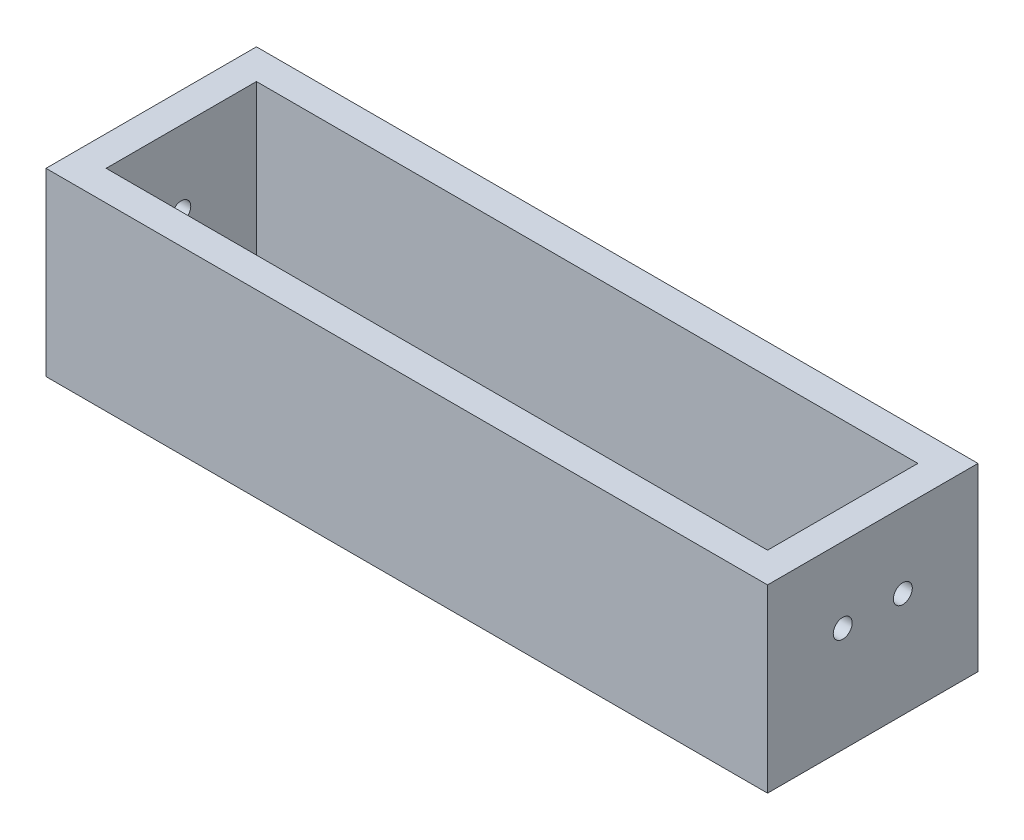
from build123d import *

# Parameters (mm, degrees)
SKETCH1_W           = 76.2
SKETCH1_H           = 22.225
BOSS_EXTRUDE1_DEPTH = 3.175
SKETCH2_W           = 3.175
SKETCH2_H           = 15.875
BOSS_EXTRUDE2_DEPTH = 15.875
SKETCH3_R           = 1
CUT_EXTRUDE1_DEPTH  = 4.175
SKETCH4_R           = 1
CUT_EXTRUDE2_DEPTH  = 4.175


with BuildPart() as part:
    # Sketch1 → Boss-Extrude1 (new body)
    with BuildSketch(Plane(origin=(0, 0, 0), x_dir=(1, 0, 0), z_dir=(0, 1, 0))):
        Rectangle(SKETCH1_W, SKETCH1_H)
    extrude(amount=BOSS_EXTRUDE1_DEPTH)

    # Sketch2 → Boss-Extrude2 (add)
    with BuildSketch(Plane(origin=(0, 3.175, 0), x_dir=(1, 0, 0), z_dir=(0, 1, 0))):
        Polygon((38.1, 11.1125), (-38.1, 11.1125), (-38.1, 7.9375), (-34.925, 7.9375), (34.925, 7.9375), (38.1, 7.9375), align=None)
        with Locations((-36.5125, 0)):
            Rectangle(SKETCH2_W, SKETCH2_H)
        Polygon((-34.925, -7.9375), (-38.1, -7.9375), (-38.1, -11.1125), (38.1, -11.1125), (38.1, -7.9375), (34.925, -7.9375), align=None)
        with Locations((36.5125, 0)):
            Rectangle(SKETCH2_W, SKETCH2_H)
    extrude(amount=BOSS_EXTRUDE2_DEPTH)

    # Sketch3 → Cut-Extrude1 (cut, through all)
    with BuildSketch(Plane.ZY.offset(-34.925)):
        with Locations((3.175, 11.1125)):
            Circle(SKETCH3_R)
        with Locations((-3.175, 11.1125)):
            Circle(SKETCH3_R)
    extrude(amount=-CUT_EXTRUDE1_DEPTH, mode=Mode.SUBTRACT)

    # Sketch4 → Cut-Extrude2 (cut, through all)
    with BuildSketch(Plane(origin=(-34.925, 0, 0), x_dir=(0, 0, -1), z_dir=(1, 0, 0))):
        with Locations((0, 11.1125)):
            Circle(SKETCH4_R)
    extrude(amount=-CUT_EXTRUDE2_DEPTH, mode=Mode.SUBTRACT)


solid = part.part
